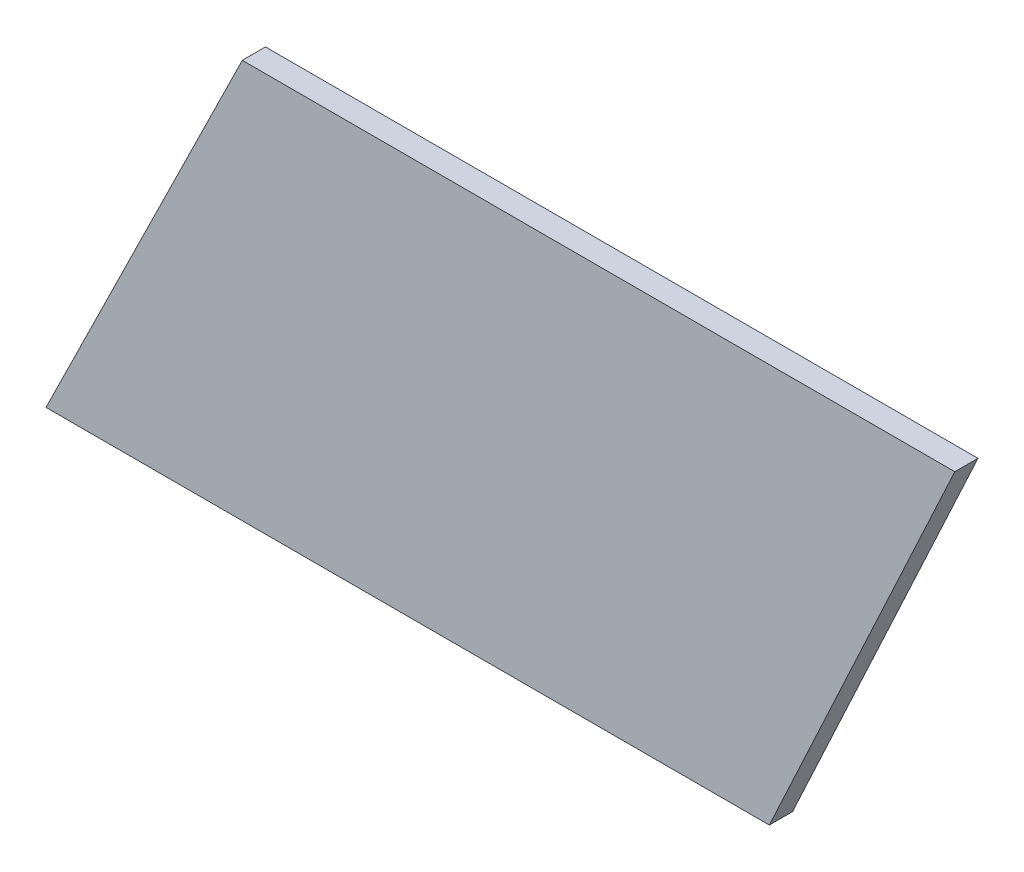
from build123d import *

# Parameters (mm, degrees)
BOSS_EXTRUDE1_DEPTH = 1.5


with BuildPart() as part:
    # Sketch1 → Boss-Extrude1 (new body)
    with BuildSketch(Plane.XY):
        Polygon((0, 0), (12, 25.8), (-34.1, 25.8), (-46.8, 0), align=None)
    extrude(amount=BOSS_EXTRUDE1_DEPTH)


solid = part.part
